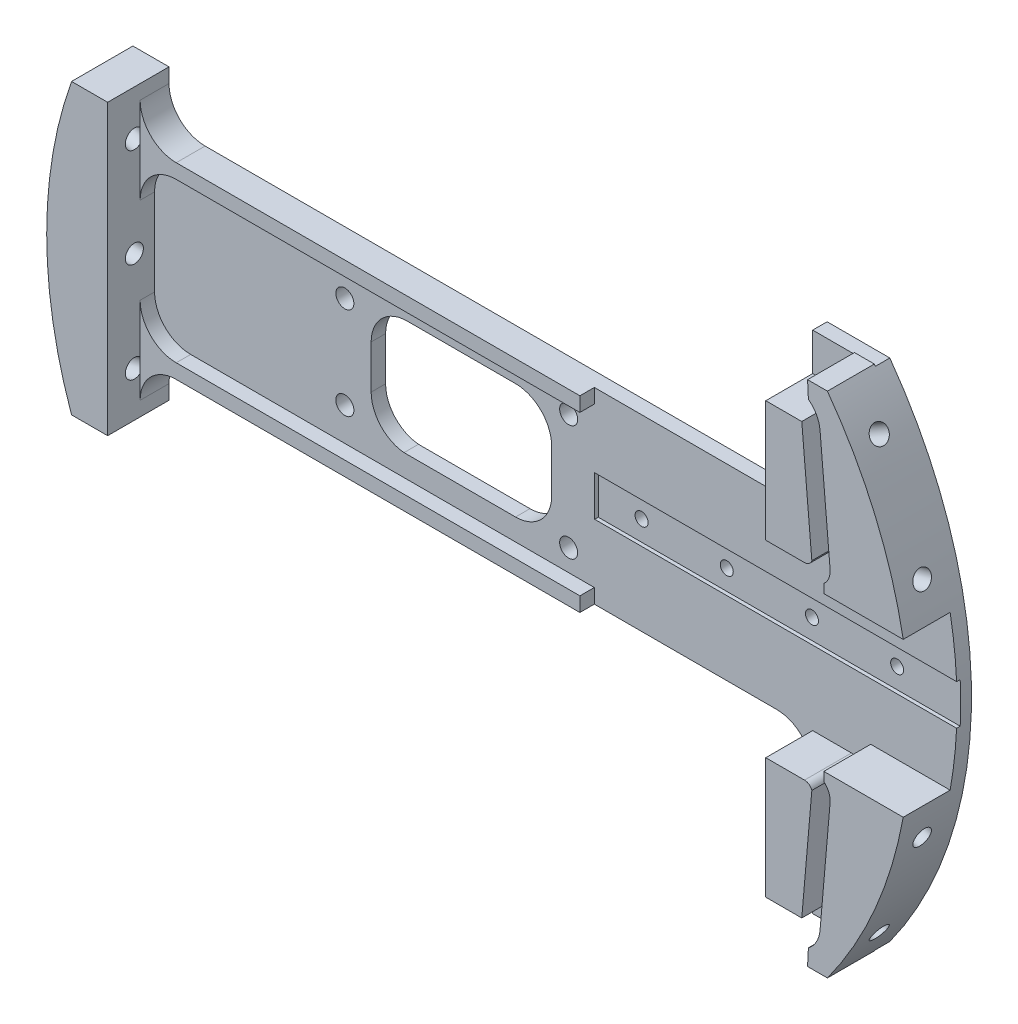
from build123d import *

# Parameters (mm, degrees)
SKETCH1_R           = 1.5875
BOSS_EXTRUDE1_DEPTH = 2.54
BOSS_EXTRUDE2_DEPTH = 8.255
SKETCH3_W           = 64.77
SKETCH3_H           = 7.1
CUT_EXTRUDE1_DEPTH  = 0.635
SKETCH9_R           = 1.5875
CUT_EXTRUDE4_DEPTH  = 3.54
SKETCH4_R           = 1.143
CUT_EXTRUDE2_DEPTH  = 11.43
BOSS_EXTRUDE5_DEPTH = 8.255
SKETCH28_R          = 1.5875
CUT_EXTRUDE12_DEPTH = 7.62
SKETCH29_R          = 1.5875
CUT_EXTRUDE13_DEPTH = 10.16
SKETCH30_R          = 1.5875
CUT_EXTRUDE14_DEPTH = 12.7
SKETCH31_R          = 1.5875
CUT_EXTRUDE15_DEPTH = 12.7
SKETCH32_R          = 1.5875
CUT_EXTRUDE16_DEPTH = 12.7
BOSS_EXTRUDE6_DEPTH = 2.54
CUT_EXTRUDE17_DEPTH = 3.5400001


with BuildPart() as part:
    # Sketch1 → Boss-Extrude1 (new body)
    with BuildSketch(Plane.XY):
        with BuildLine():
            Line((-71.572584947, 25.4), (-65.222584947, 25.4))
            Line((-65.222584947, 25.4), (-65.222584947, 22.86))
            ThreePointArc((-65.222584947, 22.86), (-63.362713008, 18.369871939), (-58.872584947, 16.51))
            Line((-58.872584947, 16.51), (44.196, 16.51))
            ThreePointArc((44.196, 16.51), (48.686128061, 18.369871939), (50.546, 22.86))
            Line((50.546, 22.86), (50.546, 44.45))
            Line((50.546, 44.45), (61.579155694, 44.45))
            ThreePointArc((61.579155694, 44.45), (75.946, 0), (61.579155694, -44.45))
            Line((61.579155694, -44.45), (50.546, -44.45))
            Line((50.546, -44.45), (50.546, -22.86))
            ThreePointArc((50.546, -22.86), (48.686128061, -18.369871939), (44.196, -16.51))
            Line((44.196, -16.51), (-58.872584947, -16.51))
            ThreePointArc((-58.872584947, -16.51), (-63.362713008, -18.369871939), (-65.222584947, -22.86))
            Line((-65.222584947, -22.86), (-65.222584947, -25.4))
            Line((-65.222584947, -25.4), (-71.572584947, -25.4))
            ThreePointArc((-71.572584947, -25.4), (-75.946, 0), (-71.572584947, 25.4))
        make_face()
        with Locations((-31.75, 8.128)):
            Circle(SKETCH1_R, mode=Mode.SUBTRACT)
        with Locations((-31.75, -8.128)):
            Circle(SKETCH1_R, mode=Mode.SUBTRACT)
    extrude(amount=BOSS_EXTRUDE1_DEPTH)

    # Sketch2 → Boss-Extrude2 (add)
    with BuildSketch(Plane.XY.offset(2.54)):
        with BuildLine():
            Line((61.865268471, 17.78), (60.095110466, 38.1))
            ThreePointArc((60.095110466, 38.1), (59.464196764, 40.158289632), (58.047089349, 41.778911391))
            Line((58.047089349, 41.778911391), (57.900800643, 44.704))
            Line((57.900800643, 44.704), (61.395010384, 44.704))
            ThreePointArc((61.395010384, 44.704), (69.822038137, 29.877715884), (74.728381149, 13.544887112))
            Line((74.728381149, 13.544887112), (60.759450402, 13.544887112))
            Line((60.759450402, 13.544887112), (60.759450402, 15.094127876))
            ThreePointArc((60.759450402, 15.094127876), (61.639191639, 16.302501703), (61.865268471, 17.78))
        make_face()
        with BuildLine():
            Line((58.651639318, 17.500047669), (56.881481313, 37.820047669))
            Line((56.881481313, 37.820047669), (50.546, 37.820047669))
            Line((50.546, 37.820047669), (50.546, 16.566735288))
            Line((50.546, 16.566735288), (57.366094516, 16.566735288))
            ThreePointArc((57.366094516, 16.566735288), (58.160401987, 16.824667019), (58.651639318, 17.500047669))
        make_face()
        with BuildLine():
            Line((60.759450402, -13.544887112), (74.728381149, -13.544887112))
            ThreePointArc((74.728381149, -13.544887112), (69.822038137, -29.877715884), (61.395010384, -44.704))
            Line((61.395010384, -44.704), (57.900800643, -44.704))
            Line((57.900800643, -44.704), (58.047089349, -41.778911391))
            ThreePointArc((58.047089349, -41.778911391), (59.464196764, -40.158289632), (60.095110466, -38.1))
            Line((60.095110466, -38.1), (61.865268471, -17.78))
            ThreePointArc((61.865268471, -17.78), (61.639191639, -16.302501703), (60.759450402, -15.094127876))
            Line((60.759450402, -15.094127876), (60.759450402, -13.544887112))
        make_face()
        with BuildLine():
            Line((50.546, -16.566735288), (57.366094516, -16.566735288))
            ThreePointArc((57.366094516, -16.566735288), (58.160401987, -16.824667019), (58.651639318, -17.500047669))
            Line((58.651639318, -17.500047669), (56.881481313, -37.820047669))
            Line((56.881481313, -37.820047669), (50.546, -37.820047669))
            Line((50.546, -37.820047669), (50.546, -16.566735288))
        make_face()
    extrude(amount=BOSS_EXTRUDE2_DEPTH)

    # Sketch3 → Cut-Extrude1 (cut)
    with BuildSketch(Plane.XY.offset(2.54)):
        with Locations((44.577, 0)):
            Rectangle(SKETCH3_W, SKETCH3_H)
    extrude(amount=-CUT_EXTRUDE1_DEPTH, mode=Mode.SUBTRACT)

    # Sketch9 → Cut-Extrude4 (cut, through all)
    with BuildSketch(Plane.XY.offset(2.54)):
        with Locations((7.62, -10.16)):
            Circle(SKETCH9_R)
        with Locations((7.62, 10.16)):
            Circle(SKETCH9_R)
    extrude(amount=-CUT_EXTRUDE4_DEPTH, mode=Mode.SUBTRACT)

    # Sketch4 → Cut-Extrude2 (cut)
    with BuildSketch(Plane.XY.offset(1.905)):
        with Locations((19.812, 0)):
            Circle(SKETCH4_R)
        with Locations((34.798, 0)):
            Circle(SKETCH4_R)
        with Locations((49.784, 0)):
            Circle(SKETCH4_R)
        with Locations((64.77, 0)):
            Circle(SKETCH4_R)
    extrude(amount=-CUT_EXTRUDE2_DEPTH, mode=Mode.SUBTRACT)

    # Sketch19 → Boss-Extrude5 (add)
    with BuildSketch(Plane.XY.offset(2.54)):
        with BuildLine():
            Line((-71.572584947, -25.4), (-65.222584947, -25.4))
            Line((-65.222584947, -25.4), (-65.222584947, 25.4))
            Line((-65.222584947, 25.4), (-71.572584947, 25.4))
            ThreePointArc((-71.572584947, 25.4), (-75.946, 0), (-71.572584947, -25.4))
        make_face()
    extrude(amount=BOSS_EXTRUDE5_DEPTH)

    # Sketch28 → Cut-Extrude12 (cut)
    with BuildSketch(Plane(origin=(65.771165316, 37.973, 0), x_dir=(0, 0, -1), z_dir=(0.866025404, 0.5, 0))):
        with Locations((-6.053310192, 0)):
            Circle(SKETCH28_R)
    cut_extrude12 = extrude(amount=-CUT_EXTRUDE12_DEPTH, mode=Mode.SUBTRACT)

    # Sketch29 → Cut-Extrude13 (cut)
    with BuildSketch(Plane(origin=(73.358202803, 19.656271199, 0), x_dir=(0, 0, -1), z_dir=(0.965925826, 0.258819045, 0))):
        with Locations((-6.096, 0)):
            Circle(SKETCH29_R)
    cut_extrude13 = extrude(amount=-CUT_EXTRUDE13_DEPTH, mode=Mode.SUBTRACT)

    # Mirror3: Cut-Extrude12, Cut-Extrude13 across plane
    add(cut_extrude12.mirror(Plane.ZX), mode=Mode.SUBTRACT)
    add(cut_extrude13.mirror(Plane.ZX), mode=Mode.SUBTRACT)

    # Sketch30 → Cut-Extrude14 (cut)
    with BuildSketch(Plane(origin=(-73.358202803, 19.656271199, 0), x_dir=(0, 0, 1), z_dir=(-0.965925826, 0.258819045, 0))):
        with Locations((6.096, 0)):
            Circle(SKETCH30_R)
    extrude(amount=-CUT_EXTRUDE14_DEPTH, mode=Mode.SUBTRACT)

    # Sketch31 → Cut-Extrude15 (cut)
    with BuildSketch(Plane.ZY.offset(75.946)):
        with Locations((6.096, 0)):
            Circle(SKETCH31_R)
    extrude(amount=-CUT_EXTRUDE15_DEPTH, mode=Mode.SUBTRACT)

    # Sketch32 → Cut-Extrude16 (cut)
    with BuildSketch(Plane(origin=(-73.358202803, -19.656271199, 0), x_dir=(0, 0, 1), z_dir=(-0.965925826, -0.258819045, 0))):
        with Locations((6.096, 0)):
            Circle(SKETCH32_R)
    extrude(amount=-CUT_EXTRUDE16_DEPTH, mode=Mode.SUBTRACT)

    # Sketch33 → Boss-Extrude6 (add)
    with BuildSketch(Plane.XY.offset(2.54)):
        with BuildLine():
            Line((12.137284041, 16.51), (-58.872584947, 16.51))
            ThreePointArc((-58.872584947, 16.51), (-63.362713008, 18.369871939), (-65.222584947, 22.86))
            Line((-65.222584947, 22.86), (-65.222584947, 7.62))
            ThreePointArc((-65.222584947, 7.62), (-63.362713008, 12.110128061), (-58.872584947, 13.97))
            Line((-58.872584947, 13.97), (12.137284041, 13.97))
            Line((12.137284041, 13.97), (12.137284041, 16.51))
        make_face()
        with BuildLine():
            Line((12.137284041, -13.97), (12.137284041, -16.51))
            Line((12.137284041, -16.51), (-58.872584947, -16.51))
            ThreePointArc((-58.872584947, -16.51), (-63.362713008, -18.369871939), (-65.222584947, -22.86))
            Line((-65.222584947, -22.86), (-65.222584947, -7.62))
            ThreePointArc((-65.222584947, -7.62), (-63.362713008, -12.110128061), (-58.872584947, -13.97))
            Line((-58.872584947, -13.97), (12.137284041, -13.97))
        make_face()
    extrude(amount=BOSS_EXTRUDE6_DEPTH)

    # Sketch34 → Cut-Extrude17 (cut, through all)
    with BuildSketch(Plane.XY.offset(2.54)):
        with BuildLine():
            Line((-20.772584947, 10.16), (-1.722584947, 10.16))
            ThreePointArc((-1.722584947, 10.16), (2.767543114, 8.300128061), (4.627415053, 3.81))
            Line((4.627415053, 3.81), (4.627415053, -3.81))
            ThreePointArc((4.627415053, -3.81), (2.767543114, -8.300128061), (-1.722584947, -10.16))
            Line((-1.722584947, -10.16), (-21.339131073, -10.16))
            ThreePointArc((-21.339131073, -10.16), (-25.458738375, -8.120468891), (-27.122584947, -3.83532408))
            Line((-27.122584947, -3.83532408), (-27.122584947, 3.81))
            ThreePointArc((-27.122584947, 3.81), (-25.262713008, 8.300128061), (-20.772584947, 10.16))
        make_face()
    extrude(amount=-CUT_EXTRUDE17_DEPTH, mode=Mode.SUBTRACT)


solid = part.part
